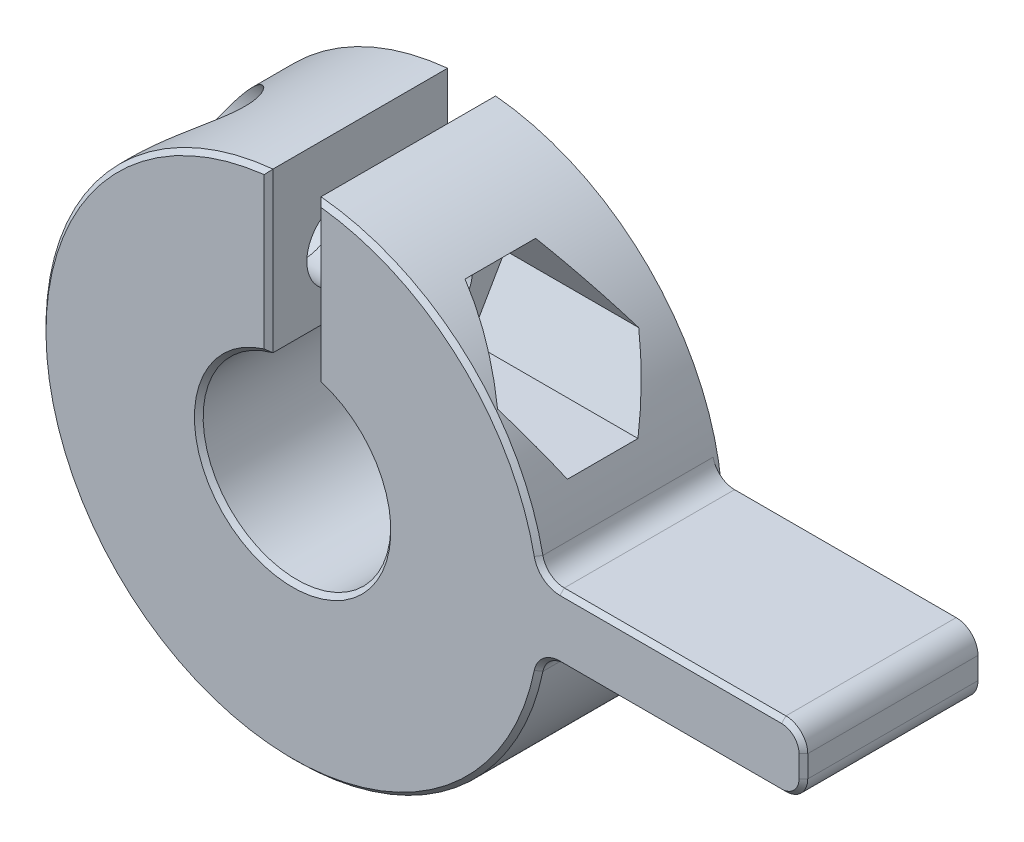
from build123d import *

# Parameters (mm, degrees)
BOSS_EXTRUDE1_DEPTH     = 15
CUT_EXTRUDE4_START      = -3
SKETCH4_R               = 3
SKETCH4_R_2             = 1.75
CUT_EXTRUDE4_DEPTH      = 15
SKETCH4_2_R             = 1.75
CUT_EXTRUDE5_DEPTH      = 12.5000001
CUT_EXTRUDE5_DEPTH_BACK = 12.5000001
CUT_EXTRUDE6_START      = 3
CUT_EXTRUDE6_DEPTH      = 15
SKETCH6_R               = 14
CUT_EXTRUDE7_DEPTH      = 6.8
SKETCH7_W               = 12
SKETCH7_H               = 3
BOSS_EXTRUDE2_DEPTH     = 8
FILLET1_R               = 1
CHAMFER2_SIZE           = 0.2


with BuildPart() as part:
    # Sketch1 → Boss-Extrude1 (new body)
    with BuildSketch(Plane.XY):
        with BuildLine():
            Line((1.1, 11.447270417), (1.1, 4.156921938))
            ThreePointArc((1.1, 4.156921938), (3.407345007, 2.62297541), (4.3, 0))
            ThreePointArc((4.3, 0), (-2.62297541, -3.407345007), (-1.1, 4.156921938))
            Line((-1.1, 4.156921938), (-1.1, 11.447270417))
            ThreePointArc((-1.1, 11.447270417), (-7.733045972, -8.511756575), (11.5, 0))
            ThreePointArc((11.5, 0), (8.511756575, 7.733045972), (1.1, 11.447270417))
        make_face()
    extrude(amount=BOSS_EXTRUDE1_DEPTH)

    # Sketch4 → Cut-Extrude4 (cut)
    with BuildSketch(Plane(origin=(0, 0, 0), x_dir=(0, 0, -1), z_dir=(1, 0, 0)).offset(CUT_EXTRUDE4_START)):
        with Locations((-11.5, 7)):
            Circle(SKETCH4_R)
        with Locations((-11.5, 7)):
            Circle(SKETCH4_R_2, mode=Mode.SUBTRACT)
        with Locations((-3.5, 7)):
            Circle(SKETCH4_R)
        with Locations((-3.5, 7)):
            Circle(SKETCH4_R_2, mode=Mode.SUBTRACT)
    extrude(amount=-CUT_EXTRUDE4_DEPTH, mode=Mode.SUBTRACT)

    # Sketch4_2 → Cut-Extrude5 (cut, two sides)
    with BuildSketch(Plane(origin=(0, 0, 0), x_dir=(0, 0, -1), z_dir=(1, 0, 0))) as cut_extrude5_sk:
        with Locations((-11.5, 7)):
            Circle(SKETCH4_2_R)
        with Locations((-3.5, 7)):
            Circle(SKETCH4_2_R)
    extrude(amount=CUT_EXTRUDE5_DEPTH, mode=Mode.SUBTRACT)
    extrude(cut_extrude5_sk.sketch, amount=-CUT_EXTRUDE5_DEPTH_BACK, mode=Mode.SUBTRACT)

    # Sketch5 → Cut-Extrude6 (cut)
    with BuildSketch(Plane(origin=(0, 0, 0), x_dir=(0, 0, -1), z_dir=(1, 0, 0)).offset(CUT_EXTRUDE6_START)):
        Polygon((-9.883419246, 9.8), (-13.116580754, 9.8), (-14.733161507, 7), (-13.116580754, 4.2), (-9.883419246, 4.2), (-8.266838493, 7), align=None)
        Polygon((-1.883419246, 9.8), (-5.116580754, 9.8), (-6.733161507, 7), (-5.116580754, 4.2), (-1.883419246, 4.2), (-0.266838493, 7), align=None)
    extrude(amount=CUT_EXTRUDE6_DEPTH, mode=Mode.SUBTRACT)

    # Sketch6 → Cut-Extrude7 (cut)
    with BuildSketch(Plane(origin=(0, 0, 0), x_dir=(-1, 0, 0), z_dir=(0, 0, -1))):
        Circle(SKETCH6_R)
    extrude(amount=-CUT_EXTRUDE7_DEPTH, mode=Mode.SUBTRACT)

    # Sketch7 → Boss-Extrude2 (add)
    with BuildSketch(Plane.XY.offset(15)):
        with Locations((17.401754251, 0)):
            Rectangle(SKETCH7_W, SKETCH7_H)
    extrude(amount=-BOSS_EXTRUDE2_DEPTH)

    # Fillet1
    fillet1_edges = [part.edges().sort_by_distance(p)[0] for p in [
        (11.401754251, -1.5, 11),
        (11.401754251, 1.5, 11),
        (23.401754251, 1.5, 11),
        (23.401754251, -1.5, 11),
    ]]
    fillet(fillet1_edges, radius=FILLET1_R)

    # Chamfer2
    chamfer2_edges = [part.edges().sort_by_distance(p)[0] for p in [
        (-8.549394828, -7.691413919, 15),
        (23.401754251, 0, 15),
        (17.324601482, -1.5, 15),
        (17.324601482, 1.5, 15),
        (7.691413919, 8.549394828, 15),
        (23.108861032, -1.207106781, 15),
        (23.108861032, 1.207106781, 15),
        (11.614993182, -1.725403331, 15),
        (11.614993182, 1.725403331, 15),
        (1.1, 7.802096178, 15),
        (0, -4.3, 15),
        (-1.1, 7.802096178, 15),
    ]]
    chamfer(chamfer2_edges, length=CHAMFER2_SIZE)


solid = part.part
